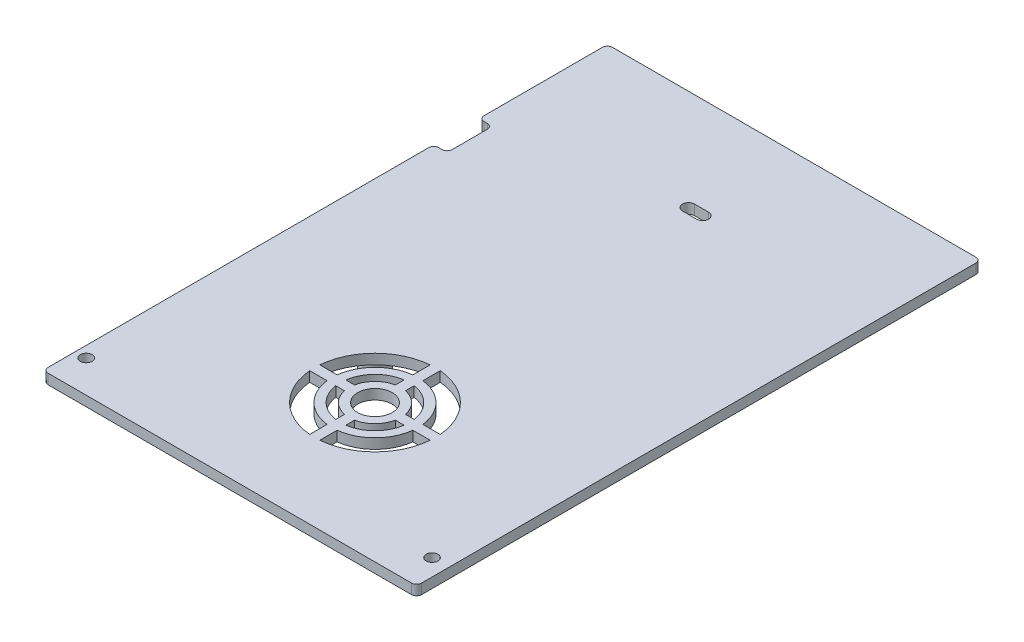
from build123d import *

# Parameters (mm, degrees)
ESBO_O1_R                = 5.145
RESSALTO_EXTRUS_O1_DEPTH = 3
ESBO_O2_R                = 1.75
CORTE_EXTRUS_O1_DEPTH    = 4
FILETE1_R                = 1.5
ESBO_O3_R                = 3.7
RESSALTO_EXTRUS_O2_DEPTH = 4.2
ESBO_O4_R                = 2.2
CORTE_EXTRUS_O2_DEPTH    = 4.2


with BuildPart() as part:
    # Esboço1 → Ressalto-extrusão1 (new body)
    with BuildSketch(Plane(origin=(0, 0, 0), x_dir=(1, 0, 0), z_dir=(0, 1, 0))):
        Polygon((-55.63, 45.795), (-55.63, 84.055), (55.63, 84.055), (55.63, -84.055), (-55.63, -84.055), (-55.63, 32.315), (-51.63, 32.315), (-51.63, 45.795), align=None)
        with Locations((2.13, -42.945)):
            Circle(ESBO_O1_R, mode=Mode.SUBTRACT)
        with BuildLine():
            Line((0.63, -53.125083497), (0.63, -50.511755976))
            ThreePointArc((0.63, -50.511755976), (-3.32462171, -48.39962171), (-5.436755976, -44.445))
            Line((-5.436755976, -44.445), (-8.050083497, -44.445))
            ThreePointArc((-8.050083497, -44.445), (-5.146128778, -50.221128778), (0.63, -53.125083497))
        make_face(mode=Mode.SUBTRACT)
        with BuildLine():
            Line((0.63, -60.882391115), (0.63, -55.717219854))
            ThreePointArc((0.63, -55.717219854), (-6.963393206, -52.038393206), (-10.642219854, -44.445))
            Line((-10.642219854, -44.445), (-15.807391115, -44.445))
            ThreePointArc((-15.807391115, -44.445), (-10.597922061, -55.672922061), (0.63, -60.882391115))
        make_face(mode=Mode.SUBTRACT)
        with BuildLine():
            Line((3.63, -60.882391115), (3.63, -55.717219854))
            ThreePointArc((3.63, -55.717219854), (11.223393206, -52.038393206), (14.902219854, -44.445))
            Line((14.902219854, -44.445), (20.067391115, -44.445))
            ThreePointArc((20.067391115, -44.445), (14.857922061, -55.672922061), (3.63, -60.882391115))
        make_face(mode=Mode.SUBTRACT)
        with BuildLine():
            Line((3.63, -53.125083497), (3.63, -50.511755976))
            ThreePointArc((3.63, -50.511755976), (7.58462171, -48.39962171), (9.696755976, -44.445))
            Line((9.696755976, -44.445), (12.310083497, -44.445))
            ThreePointArc((12.310083497, -44.445), (9.406128778, -50.221128778), (3.63, -53.125083497))
        make_face(mode=Mode.SUBTRACT)
        with BuildLine():
            Line((14.902219854, -41.445), (20.067391115, -41.445))
            ThreePointArc((20.067391115, -41.445), (14.857922061, -30.217077939), (3.63, -25.007608885))
            Line((3.63, -25.007608885), (3.63, -30.172780146))
            ThreePointArc((3.63, -30.172780146), (11.223393206, -33.851606794), (14.902219854, -41.445))
        make_face(mode=Mode.SUBTRACT)
        with BuildLine():
            Line((-15.807391115, -41.445), (-10.642219854, -41.445))
            ThreePointArc((-10.642219854, -41.445), (-6.963393206, -33.851606794), (0.63, -30.172780146))
            Line((0.63, -30.172780146), (0.63, -25.007608885))
            ThreePointArc((0.63, -25.007608885), (-10.597922061, -30.217077939), (-15.807391115, -41.445))
        make_face(mode=Mode.SUBTRACT)
        with BuildLine():
            Line((-8.050083497, -41.445), (-5.436755976, -41.445))
            ThreePointArc((-5.436755976, -41.445), (-3.32462171, -37.49037829), (0.63, -35.378244024))
            Line((0.63, -35.378244024), (0.63, -32.764916503))
            ThreePointArc((0.63, -32.764916503), (-5.146128778, -35.668871222), (-8.050083497, -41.445))
        make_face(mode=Mode.SUBTRACT)
        with BuildLine():
            Line((3.63, -35.378244024), (3.63, -32.764916503))
            ThreePointArc((3.63, -32.764916503), (9.406128778, -35.668871222), (12.310083497, -41.445))
            Line((12.310083497, -41.445), (9.696755976, -41.445))
            ThreePointArc((9.696755976, -41.445), (7.58462171, -37.49037829), (3.63, -35.378244024))
        make_face(mode=Mode.SUBTRACT)
    extrude(amount=RESSALTO_EXTRUS_O1_DEPTH)

    # Esboço2 → Corte-extrusão1 (cut, through all)
    with BuildSketch(Plane(origin=(0, 3, 0), x_dir=(1, 0, 0), z_dir=(0, 1, 0))):
        with Locations((-52.37, -74.445)):
            Circle(ESBO_O2_R)
        with Locations((50.63, -74.445)):
            Circle(ESBO_O2_R)
        with BuildLine():
            Line((-1.47, 55.855), (2.73, 55.855))
            ThreePointArc((2.73, 55.855), (4.53, 54.055), (2.73, 52.255))
            Line((2.73, 52.255), (-1.47, 52.255))
            ThreePointArc((-1.47, 52.255), (-3.27, 54.055), (-1.47, 55.855))
        make_face()
    extrude(amount=-CORTE_EXTRUS_O1_DEPTH, mode=Mode.SUBTRACT)

    # Filete1
    filete1_edges = [part.edges().sort_by_distance(p)[0] for p in [
        (-51.63, 1.5, -45.795),
        (-55.63, 1.5, -45.795),
        (-55.63, 1.5, -84.055),
        (55.63, 1.5, -84.055),
        (55.63, 1.5, 84.055),
        (-55.63, 1.5, 84.055),
        (-55.63, 1.5, -32.315),
        (-51.63, 1.5, -32.315),
    ]]
    fillet(filete1_edges, radius=FILETE1_R)

    # Esboço3 → Ressalto-extrusão2 (add)
    with BuildSketch(Plane.XZ):
        with Locations((18.13, 26.945)):
            Circle(ESBO_O3_R)
        with Locations((18.13, 58.945)):
            Circle(ESBO_O3_R)
        with Locations((-13.87, 58.945)):
            Circle(ESBO_O3_R)
        with Locations((-13.87, 26.945)):
            Circle(ESBO_O3_R)
    extrude(amount=RESSALTO_EXTRUS_O2_DEPTH)

    # Esboço4 → Corte-extrusão2 (cut)
    with BuildSketch(Plane.XZ.offset(4.2)):
        with Locations((-13.87, 58.945)):
            Circle(ESBO_O4_R)
        with Locations((18.13, 58.945)):
            Circle(ESBO_O4_R)
        with Locations((18.13, 26.945)):
            Circle(ESBO_O4_R)
        with Locations((-13.87, 26.945)):
            Circle(ESBO_O4_R)
    extrude(amount=-CORTE_EXTRUS_O2_DEPTH, mode=Mode.SUBTRACT)


solid = part.part
